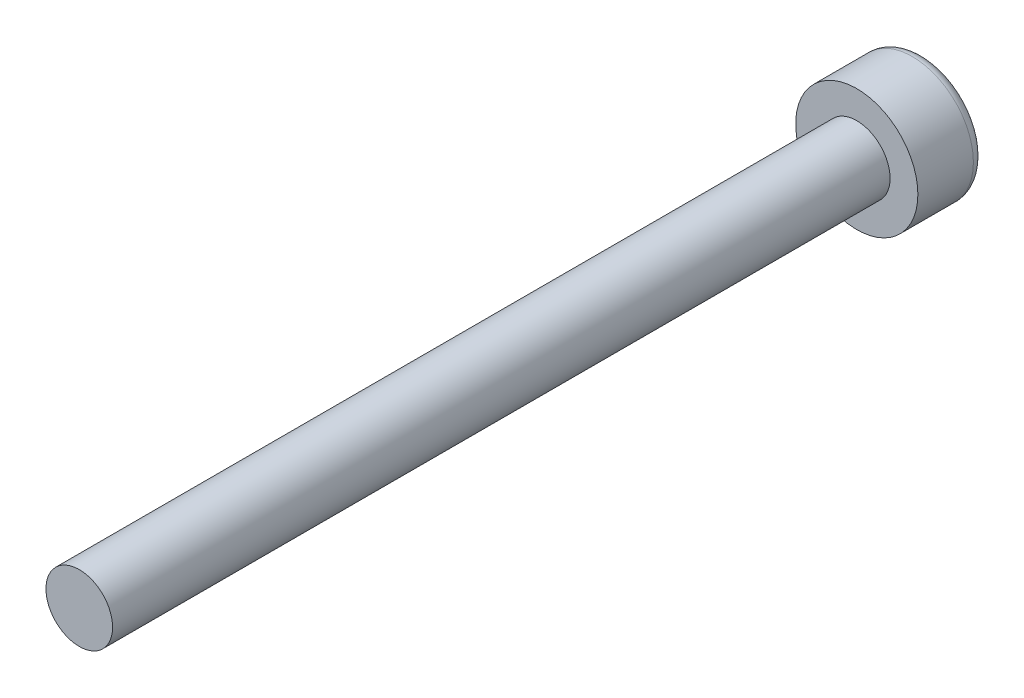
from build123d import *

# Parameters (mm, degrees)
SKETCH_2_R      = 2.75
EXTRUDE_1_DEPTH = 3
SKETCH_3_R      = 1.5
EXTRUDE_2_DEPTH = 35
FILLET_1_R      = 0.5


with BuildPart() as part:
    # ｽｹｯﾁ2 → ﾎﾞｽ - 押し出し1 (new body)
    with BuildSketch(Plane.XY):
        Circle(SKETCH_2_R)
    extrude(amount=EXTRUDE_1_DEPTH)

    # ｽｹｯﾁ3 → ﾎﾞｽ - 押し出し2 (add)
    with BuildSketch(Plane.XY.offset(3)):
        Circle(SKETCH_3_R)
    extrude(amount=EXTRUDE_2_DEPTH)

    # ﾌｨﾚｯﾄ1
    fillet_1_edges = [part.edges().sort_by_distance(p)[0] for p in [
        (-2.75, 0, 0),
    ]]
    fillet(fillet_1_edges, radius=FILLET_1_R)


solid = part.part
